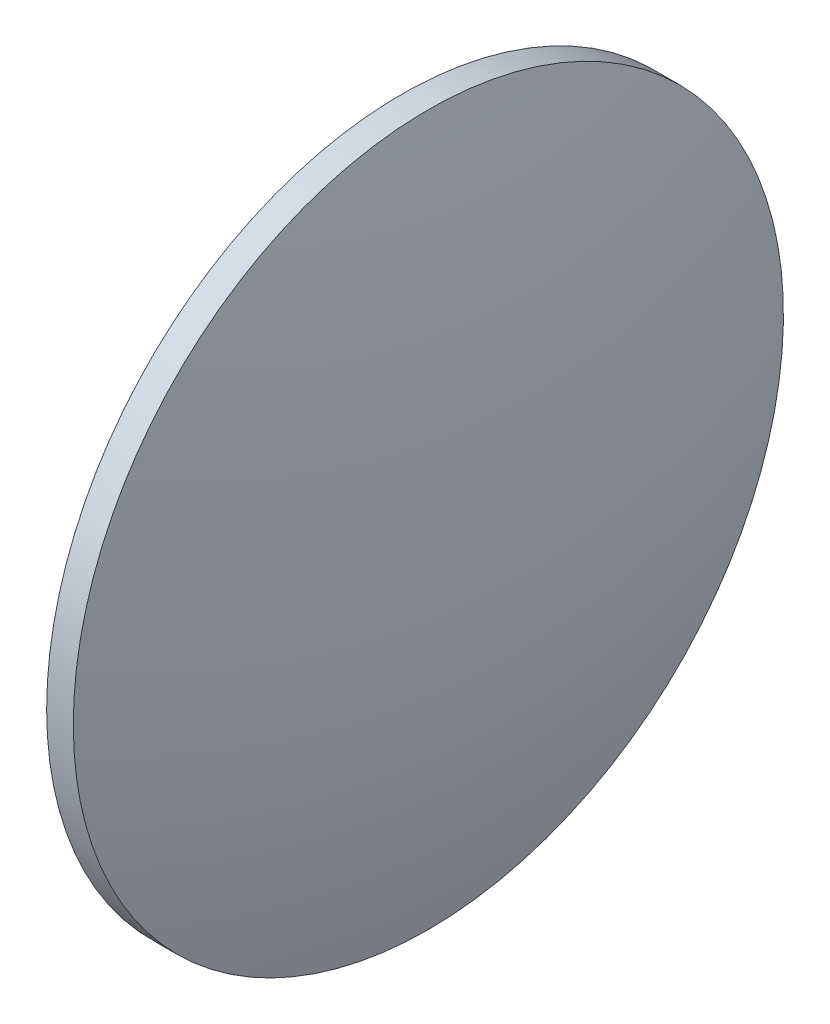
from build123d import *


with BuildPart() as part:
    # 草图1 → 旋转1 (revolve)
    with BuildSketch(Plane.XY, mode=Mode.PRIVATE) as revolve_1_sk:
        with BuildLine():
            Line((225.949094224, 130.467109853), (225.949094224, 170.467109853))
            Line((225.949094224, 170.467109853), (228.949094224, 170.467109853))
            ThreePointArc((228.949094224, 170.467109853), (232.880989927, 150.638639914), (234.199094224, 130.467109853))
            Line((234.199094224, 130.467109853), (225.949094224, 130.467109853))
        make_face()
    revolve(revolve_1_sk.sketch.rotate(Axis((217.994582532, 130.467109853, 0), (1, 0, 0)), 180), axis=Axis((217.994582532, 130.467109853, 0), (1, 0, 0)))  # turned: the seam where the file's is


solid = part.part
